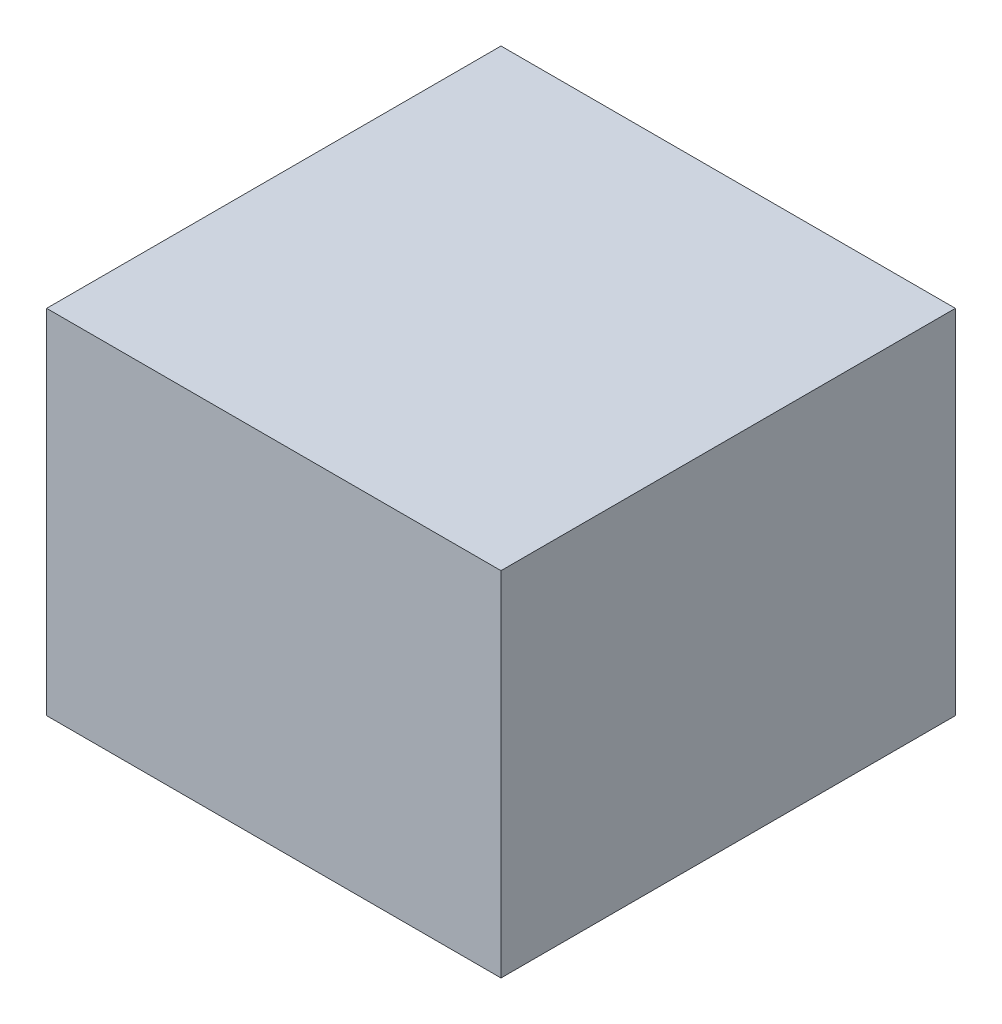
from build123d import *

# Parameters (mm, degrees)
SKETCH2_W           = 32.2
SKETCH2_H           = 32.2
BOSS_EXTRUDE1_DEPTH = 25


with BuildPart() as part:
    # Sketch2 → Boss-Extrude1 (new body)
    with BuildSketch(Plane(origin=(0, 0, 0), x_dir=(1, 0, 0), z_dir=(0, 1, 0))):
        Rectangle(SKETCH2_W, SKETCH2_H)
    extrude(amount=BOSS_EXTRUDE1_DEPTH)


solid = part.part
